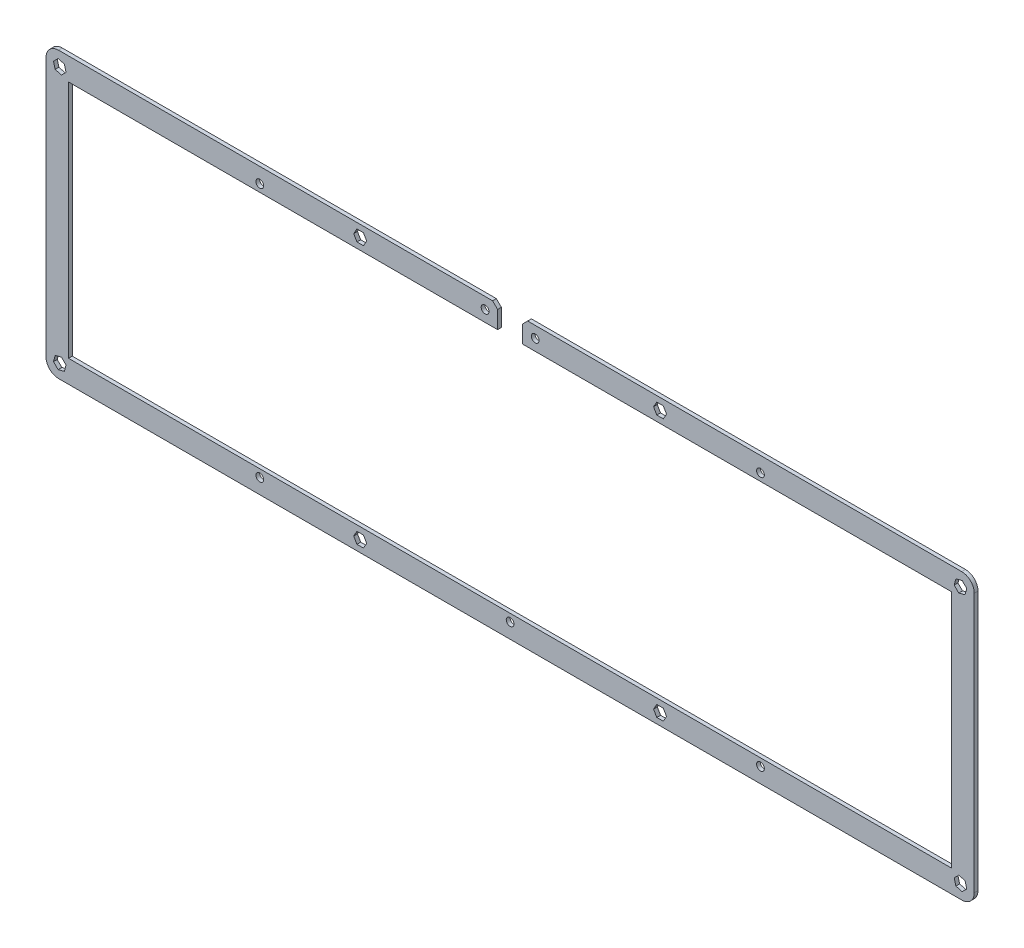
from build123d import *

# Parameters (mm, degrees)
MODEL_R             = 1.55
BOSS_EXTRUDE1_DEPTH = 1.5


with BuildPart() as part:
    # Model → Boss-Extrude1 (new body)
    with BuildSketch(Plane.XY):
        with BuildLine():
            Line((0, 108.6), (0, 5))
            ThreePointArc((0, 5), (1.464466094, 1.464466094), (5, 0))
            Line((5, 0), (365.775, 0))
            ThreePointArc((365.775, 0), (369.310533906, 1.464466094), (370.775, 5))
            Line((370.775, 5), (370.775, 108.6))
            ThreePointArc((370.775, 108.6), (369.310533906, 112.135533906), (365.775, 113.6))
            Line((365.775, 113.6), (192.3875, 113.6))
            Line((192.3875, 113.6), (190.3875, 111.6))
            Line((190.3875, 111.6), (190.3875, 104.6))
            Line((190.3875, 104.6), (361.775, 104.6))
            Line((361.775, 104.6), (361.775, 9))
            Line((361.775, 9), (9, 9))
            Line((9, 9), (9, 104.6))
            Line((9, 104.6), (180.3875, 104.6))
            Line((180.3875, 104.6), (180.3875, 111.6))
            Line((180.3875, 111.6), (178.3875, 113.6))
            Line((178.3875, 113.6), (5, 113.6))
            ThreePointArc((5, 113.6), (1.464466094, 112.135533906), (0, 108.6))
        make_face()
        with Locations((195.3875, 109.1)):
            Circle(MODEL_R, mode=Mode.SUBTRACT)
        with Locations((175.3875, 109.1)):
            Circle(MODEL_R, mode=Mode.SUBTRACT)
        with Locations((85.3875, 107.6)):
            Circle(MODEL_R, mode=Mode.SUBTRACT)
        with Locations((285.3875, 107.6)):
            Circle(MODEL_R, mode=Mode.SUBTRACT)
        with Locations((85.3875, 6)):
            Circle(MODEL_R, mode=Mode.SUBTRACT)
        with Locations((185.3875, 6)):
            Circle(MODEL_R, mode=Mode.SUBTRACT)
        with Locations((285.3875, 6)):
            Circle(MODEL_R, mode=Mode.SUBTRACT)
        Polygon((365.947431604, 110.609548911), (367.784548911, 108.772431604), (367.112117307, 106.262882693), (364.602568396, 105.590451089), (362.765451089, 107.427568396), (363.437882693, 109.937117307), align=None, mode=Mode.SUBTRACT)
        Polygon((4.827568396, 110.609548911), (2.990451089, 108.772431604), (3.662882693, 106.262882693), (6.172431604, 105.590451089), (8.009548911, 107.427568396), (7.337117307, 109.937117307), align=None, mode=Mode.SUBTRACT)
        Polygon((365.947431604, 2.990451089), (367.784548911, 4.827568396), (367.112117307, 7.337117307), (364.602568396, 8.009548911), (362.765451089, 6.172431604), (363.437882693, 3.662882693), align=None, mode=Mode.SUBTRACT)
        Polygon((4.827568396, 2.990451089), (2.990451089, 4.827568396), (3.662882693, 7.337117307), (6.172431604, 8.009548911), (8.009548911, 6.172431604), (7.337117307, 3.662882693), align=None, mode=Mode.SUBTRACT)
        Polygon((243.975961894, 2.25), (246.574038106, 2.25), (247.873076211, 4.5), (246.574038106, 6.75), (243.975961894, 6.75), (242.676923789, 4.5), align=None, mode=Mode.SUBTRACT)
        Polygon((243.975961894, 106.85), (246.574038106, 106.85), (247.873076211, 109.1), (246.574038106, 111.35), (243.975961894, 111.35), (242.676923789, 109.1), align=None, mode=Mode.SUBTRACT)
        Polygon((124.200961894, 106.85), (126.799038106, 106.85), (128.098076211, 109.1), (126.799038106, 111.35), (124.200961894, 111.35), (122.901923789, 109.1), align=None, mode=Mode.SUBTRACT)
        Polygon((124.200961894, 2.25), (126.799038106, 2.25), (128.098076211, 4.5), (126.799038106, 6.75), (124.200961894, 6.75), (122.901923789, 4.5), align=None, mode=Mode.SUBTRACT)
    extrude(amount=BOSS_EXTRUDE1_DEPTH)


solid = part.part
